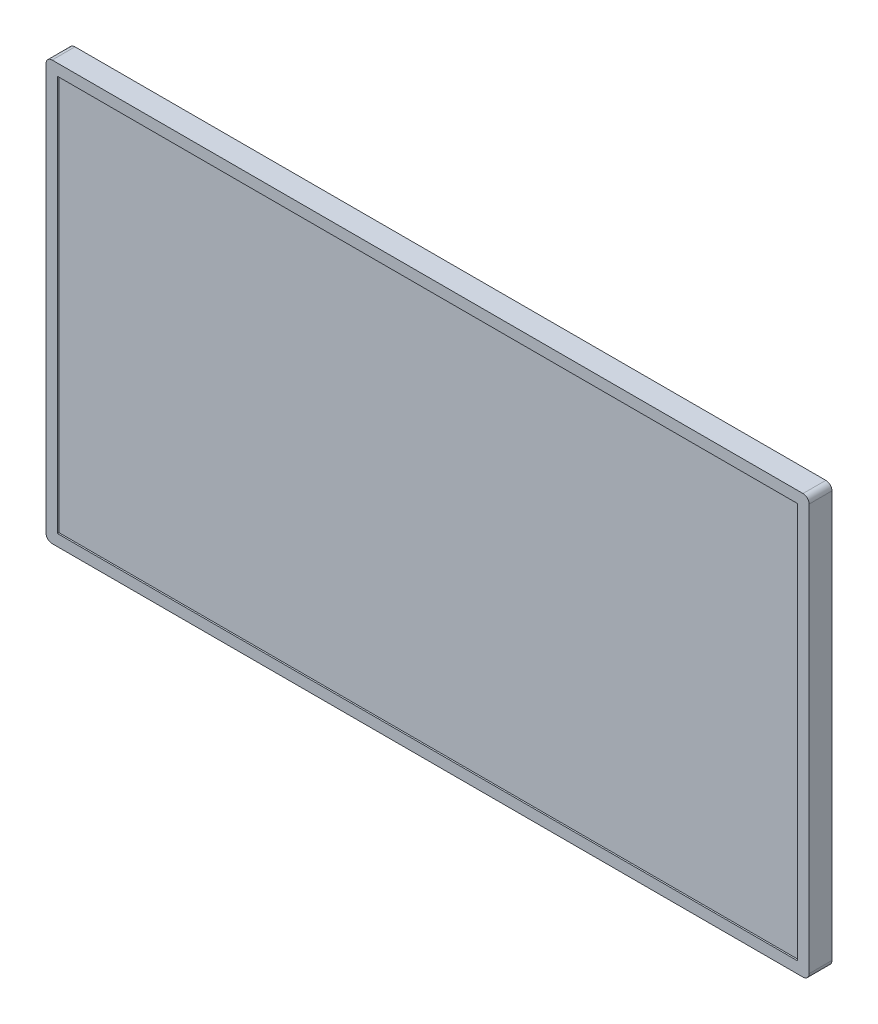
from build123d import *

# Parameters (mm, degrees)
CROQUIS1_W              = 1001.972554514
CROQUIS1_H              = 550
SALIENTE_EXTRUIR1_DEPTH = 30
CROQUIS2_W              = 971.972554514
CROQUIS2_H              = 520
CORTAR_EXTRUIR1_DEPTH   = 2
REDONDEO1_R             = 8


with BuildPart() as part:
    # Croquis1 → Saliente-Extruir1 (new body)
    with BuildSketch(Plane.XY):
        with Locations((500.986277257, 275)):
            Rectangle(CROQUIS1_W, CROQUIS1_H)
    extrude(amount=SALIENTE_EXTRUIR1_DEPTH)

    # Croquis2 → Cortar-Extruir1 (cut)
    with BuildSketch(Plane.XY.offset(30)):
        with Locations((500.986277257, 275)):
            Rectangle(CROQUIS2_W, CROQUIS2_H)
    extrude(amount=-CORTAR_EXTRUIR1_DEPTH, mode=Mode.SUBTRACT)

    # Redondeo1
    redondeo1_edges = [part.edges().sort_by_distance(p)[0] for p in [
        (0, 550, 15),
        (1001.972554514, 550, 15),
        (1001.972554514, 0, 15),
        (0, 0, 15),
    ]]
    fillet(redondeo1_edges, radius=REDONDEO1_R)


solid = part.part
